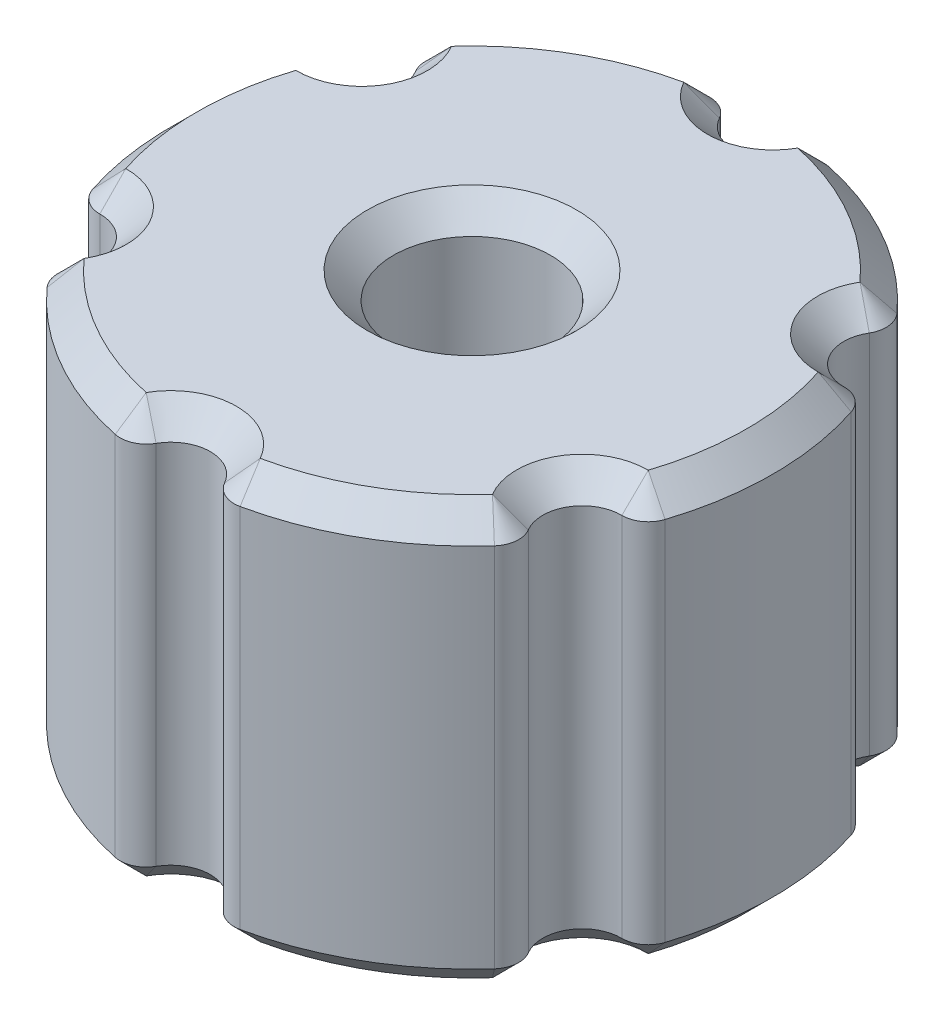
from build123d import *

# Parameters (mm, degrees)
ESBO_O1_R                  = 11.5
ESBO_O1_R_2                = 3
RESSALTO_EXTRUS_O1_DEPTH   = 16
ESBO_O2_R                  = 1.50344291
CORTE_EXTRUS_O1_DEPTH      = 1
CORTE_EXTRUS_O1_DEPTH_BACK = 17
FILETE2_R                  = 1
CHANFRO1_SIZE              = 1


with BuildPart() as part:
    # Esboço1 → Ressalto-extrusão1 (new body)
    with BuildSketch(Plane(origin=(0, 0, 0), x_dir=(1, 0, 0), z_dir=(0, 1, 0))):
        Circle(ESBO_O1_R)
        Circle(ESBO_O1_R_2, mode=Mode.SUBTRACT)
    extrude(amount=RESSALTO_EXTRUS_O1_DEPTH)

    # Esboço2 → Corte-extrusão1 (cut, two sides)
    with BuildSketch(Plane(origin=(0, 16, 0), x_dir=(1, 0, 0), z_dir=(0, 1, 0))) as corte_extrus_o1_sk:
        with Locations((0, 11.50344291)):
            Circle(ESBO_O2_R)
        with Locations((9.962273791, 5.751721455)):
            Circle(ESBO_O2_R)
        with Locations((9.962273791, -5.751721455)):
            Circle(ESBO_O2_R)
        with Locations((0, -11.50344291)):
            Circle(ESBO_O2_R)
        with Locations((-9.962273791, -5.751721455)):
            Circle(ESBO_O2_R)
        with Locations((-9.962273791, 5.751721455)):
            Circle(ESBO_O2_R)
    extrude(amount=CORTE_EXTRUS_O1_DEPTH, mode=Mode.SUBTRACT)
    extrude(corte_extrus_o1_sk.sketch, amount=-CORTE_EXTRUS_O1_DEPTH_BACK, mode=Mode.SUBTRACT)

    # Filete2
    filete2_edges = [part.edges().sort_by_distance(p)[0] for p in [
        (9.124208829, 8, -6.999915231),
        (10.624208829, 8, -4.40183902),
        (10.624208829, 8, 4.40183902),
        (9.124208829, 8, 6.999915231),
        (1.5, 8, 11.401754251),
        (-1.5, 8, 11.401754251),
        (-9.124208829, 8, 6.999915231),
        (-10.624208829, 8, 4.40183902),
        (-10.624208829, 8, -4.40183902),
        (-9.124208829, 8, -6.999915231),
        (-1.5, 8, -11.401754251),
        (1.5, 8, -11.401754251),
    ]]
    fillet(filete2_edges, radius=FILETE2_R)

    # Chanfro1
    chanfro1_edges = [part.edges().sort_by_distance(p)[0] for p in [
        (11.5, 0, 0),
        (11.5, 16, 0),
        (10.568864163, 0, 4.060152749),
        (10.568864163, 0, -4.060152749),
        (8.660254038, 0, 5),
        (8.660254038, 0, -5),
        (8.800627505, 0, 7.12282848),
        (8.800627505, 0, -7.12282848),
        (5.75, 0, 9.959292144),
        (5.75, 0, -9.959292144),
        (1.768236658, 0, 11.182981229),
        (1.768236658, 0, -11.182981229),
        (0, 0, 10),
        (0, 0, -10),
        (-1.768236658, 0, 11.182981229),
        (-1.768236658, 0, -11.182981229),
        (-5.75, 0, 9.959292144),
        (-5.75, 0, -9.959292144),
        (-8.800627505, 0, 7.12282848),
        (-8.800627505, 0, -7.12282848),
        (-8.660254038, 0, 5),
        (-8.660254038, 0, -5),
        (-10.568864163, 0, 4.060152749),
        (-10.568864163, 0, -4.060152749),
        (-11.5, 0, 0),
        (-3, 0, 0),
        (10.568864163, 16, 4.060152749),
        (10.568864163, 16, -4.060152749),
        (8.660254038, 16, 5),
        (8.800627505, 16, 7.12282848),
        (5.75, 16, 9.959292144),
        (1.768236658, 16, 11.182981229),
        (8.660254038, 16, -5),
        (0, 16, 10),
        (8.800627505, 16, -7.12282848),
        (-1.768236658, 16, 11.182981229),
        (5.75, 16, -9.959292144),
        (-5.75, 16, 9.959292144),
        (1.768236658, 16, -11.182981229),
        (-8.800627505, 16, 7.12282848),
        (0, 16, -10),
        (-8.660254038, 16, 5),
        (-1.768236658, 16, -11.182981229),
        (-10.568864163, 16, 4.060152749),
        (-5.75, 16, -9.959292144),
        (-11.5, 16, 0),
        (-8.800627505, 16, -7.12282848),
        (-10.568864163, 16, -4.060152749),
        (-8.660254038, 16, -5),
        (-3, 16, 0),
    ]]
    chamfer(chanfro1_edges, length=CHANFRO1_SIZE)


solid = part.part
